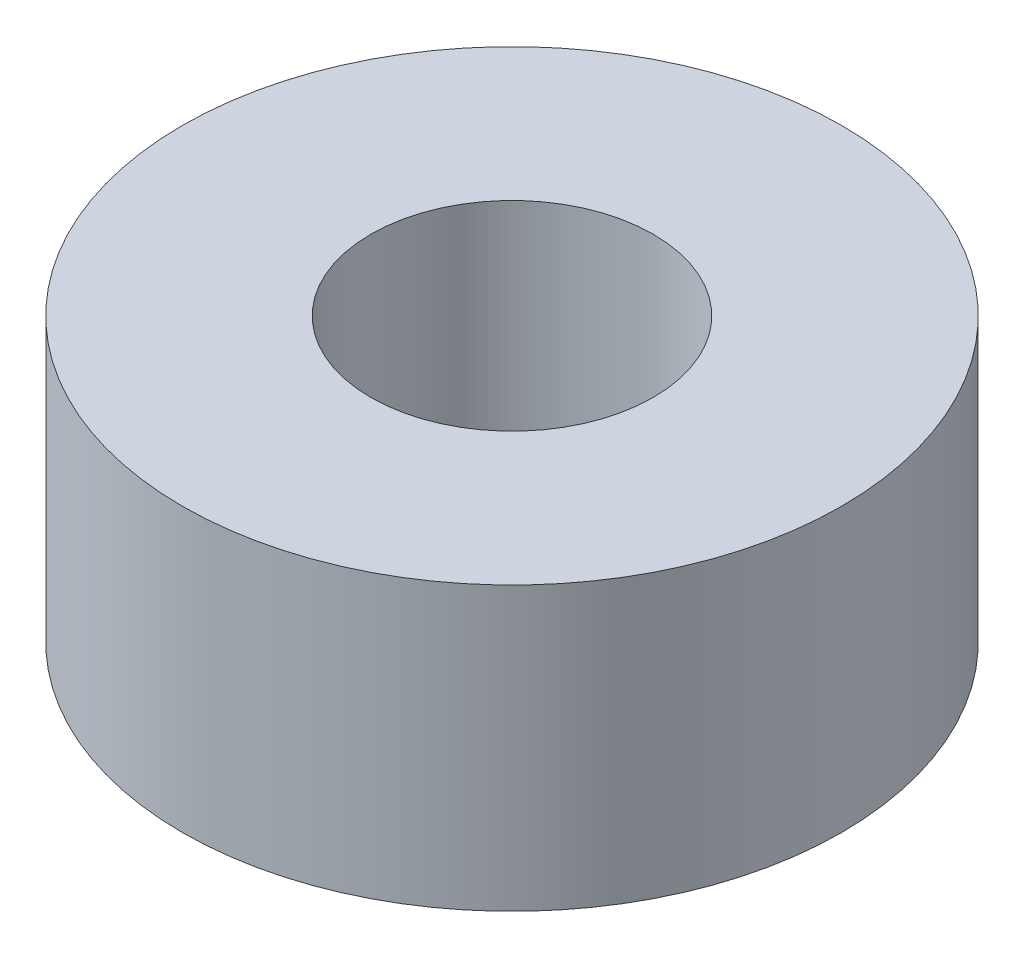
from build123d import *

# Parameters (mm, degrees)
SKETCH1_R           = 11.1125
SKETCH1_R_2         = 4.7625
BOSS_EXTRUDE1_DEPTH = 9.525


with BuildPart() as part:
    # Sketch1 → Boss-Extrude1 (new body)
    with BuildSketch(Plane(origin=(0, 0, 0), x_dir=(1, 0, 0), z_dir=(0, 1, 0))):
        Circle(SKETCH1_R)
        Circle(SKETCH1_R_2, mode=Mode.SUBTRACT)
    extrude(amount=BOSS_EXTRUDE1_DEPTH)


solid = part.part
